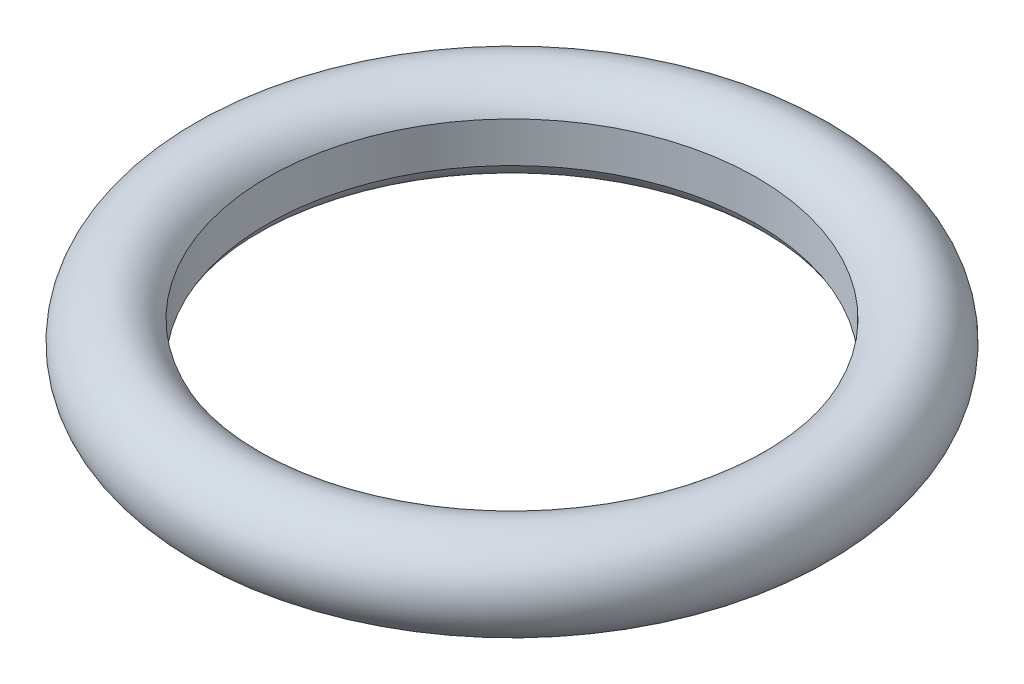
from build123d import *


with BuildPart() as part:
    # Sketch1 → Revolve1 (revolve)
    with BuildSketch(Plane.XY):
        with BuildLine():
            Line((-4.85, 0.4), (-4.85, -0.4))
            ThreePointArc((-4.85, -0.4), (-6.532927579, 0), (-4.85, 0.4))
        make_face()
    revolve(axis=Axis((0, 0, 0), (0, 1, 0)))


solid = part.part
